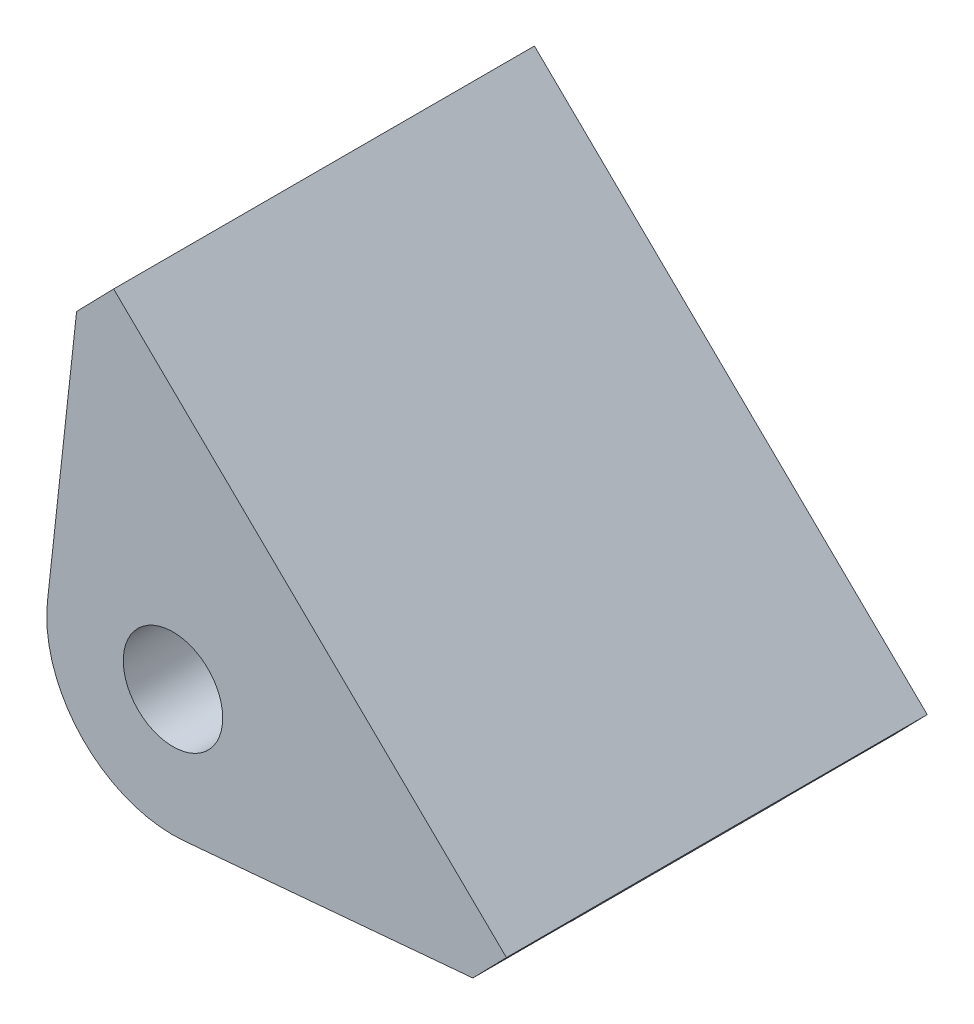
from build123d import *

# Parameters (mm, degrees)
SKETCH1_R               = 6.00075
BOSS_EXTRUDE1_DEPTH     = 12.7
BOSS_EXTRUDE2_DEPTH     = 12.7
CUT_EXTRUDE1_DEPTH      = 26.4
CUT_EXTRUDE1_DEPTH_BACK = 26.4


with BuildPart() as part:
    # Sketch1 → Boss-Extrude1 (new body)
    with BuildSketch(Plane.XY):
        with BuildLine():
            Line((-1425.647832194, 709.279769852), (-1430.049287856, 669.182201206))
            ThreePointArc((-1430.049287856, 669.182201206), (-1425.788130872, 656.855717211), (-1413.552984482, 652.338986166))
            Line((-1413.552984482, 652.338986166), (-1371.063789142, 656.110020516))
            Line((-1371.063789142, 656.110020516), (-1425.647832194, 709.279769852))
        make_face()
        with Locations((-1414.900280944, 667.519315288)):
            Circle(SKETCH1_R, mode=Mode.SUBTRACT)
        with BuildLine():
            ThreePointArc((-1399.660280943, 667.519315289), (-1414.06759413, 682.736550014), (-1430.049287856, 669.182201206))
            ThreePointArc((-1430.049287856, 669.182201206), (-1429.244352574, 662.370994293), (-1425.534230405, 656.602506283))
            ThreePointArc((-1425.534230405, 656.602506283), (-1420.009574625, 653.161295993), (-1413.552984482, 652.338986166))
            ThreePointArc((-1413.552984482, 652.338986167), (-1403.657719001, 657.230369718), (-1399.660280943, 667.519315289))
        make_face()
        with Locations((-1414.900280944, 667.519315288)):
            Circle(SKETCH1_R, mode=Mode.SUBTRACT)
    boss_extrude1 = extrude(amount=BOSS_EXTRUDE1_DEPTH)

    # Sketch2 → Boss-Extrude2 (add, symmetric)
    with BuildSketch(Plane(origin=(0, 0, -12.7), x_dir=(-1, 0, 0), z_dir=(0, 0, -1))):
        Polygon((1422.066202071, 705.790941154), (1374.645419263, 659.598849213), (1379.65176797, 654.459333665), (1404.266329264, 678.436122134), (1427.072550778, 700.651425607), align=None)
    extrude(amount=BOSS_EXTRUDE2_DEPTH, both=True)

    # Mirror2: Boss-Extrude1 across plane
    add(boss_extrude1.mirror(Plane(origin=(0, 0, -12.7), x_dir=(1, 0, 0), z_dir=(0, 0, -1))))

    # Sketch4 → Cut-Extrude1 (cut, two sides)
    with BuildSketch(Plane(origin=(0, 0, -12.7), x_dir=(-1, 0, 0), z_dir=(0, 0, -1))) as cut_extrude1_sk:
        Polygon((1376.070137849, 650.970504969), (1371.063789142, 656.110020516), (1374.645419263, 659.598849213), (1379.65176797, 654.459333665), align=None)
        Polygon((1427.072550778, 700.651425607), (1430.654180901, 704.140254305), (1425.647832194, 709.279769852), (1422.066202071, 705.790941154), align=None)
    extrude(amount=CUT_EXTRUDE1_DEPTH, mode=Mode.SUBTRACT)
    extrude(cut_extrude1_sk.sketch, amount=-CUT_EXTRUDE1_DEPTH_BACK, mode=Mode.SUBTRACT)


solid = part.part
